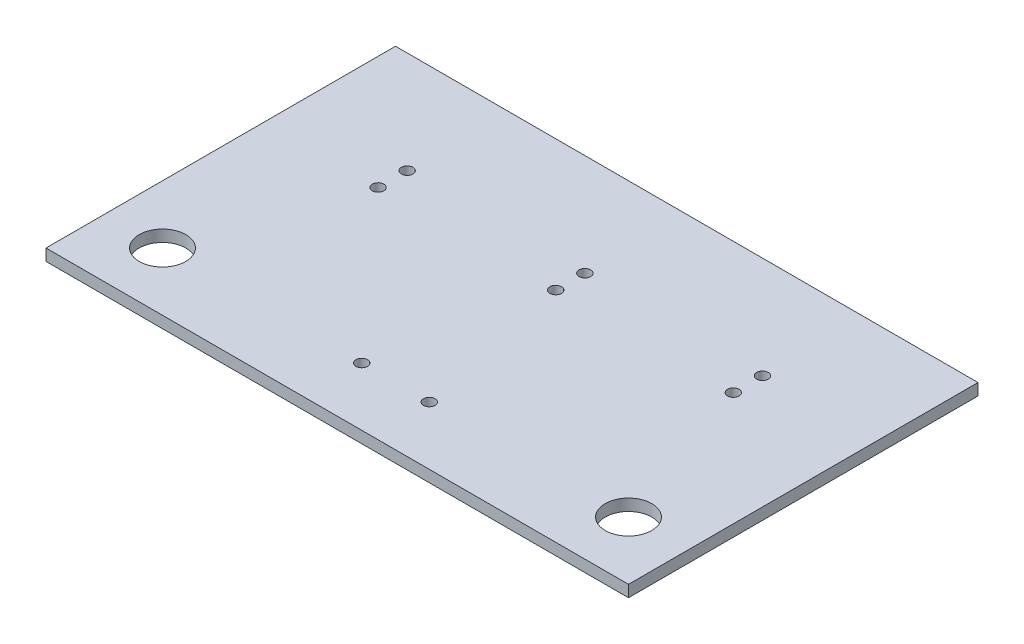
from build123d import *

# Parameters (mm, degrees)
SKETCH1_W           = 50
SKETCH1_H           = 30
BOSS_EXTRUDE1_DEPTH = 1
SKETCH2_R           = 0.5
SKETCH2_R_2         = 2
CUT_EXTRUDE1_DEPTH  = 1


with BuildPart() as part:
    # Sketch1 → Boss-Extrude1 (new body)
    with BuildSketch(Plane(origin=(0, 0, 0), x_dir=(1, 0, 0), z_dir=(0, 1, 0))):
        with Locations((25, 15)):
            Rectangle(SKETCH1_W, SKETCH1_H)
    extrude(amount=BOSS_EXTRUDE1_DEPTH)

    # Sketch2 → Cut-Extrude1 (cut)
    with BuildSketch(Plane(origin=(0, 1, 0), x_dir=(1, 0, 0), z_dir=(0, 1, 0))):
        with Locations((22.1, 5)):
            Circle(SKETCH2_R)
        with Locations((27.9, 5)):
            Circle(SKETCH2_R)
        with Locations((9.75, 18.75)):
            Circle(SKETCH2_R)
        with Locations((9.75, 21.25)):
            Circle(SKETCH2_R)
        with Locations((25, 18.75)):
            Circle(SKETCH2_R)
        with Locations((25, 21.25)):
            Circle(SKETCH2_R)
        with Locations((40.25, 18.75)):
            Circle(SKETCH2_R)
        with Locations((40.25, 21.25)):
            Circle(SKETCH2_R)
        with Locations((45, 5)):
            Circle(SKETCH2_R_2)
        with Locations((5, 5)):
            Circle(SKETCH2_R_2)
    extrude(amount=-CUT_EXTRUDE1_DEPTH, mode=Mode.SUBTRACT)


solid = part.part
